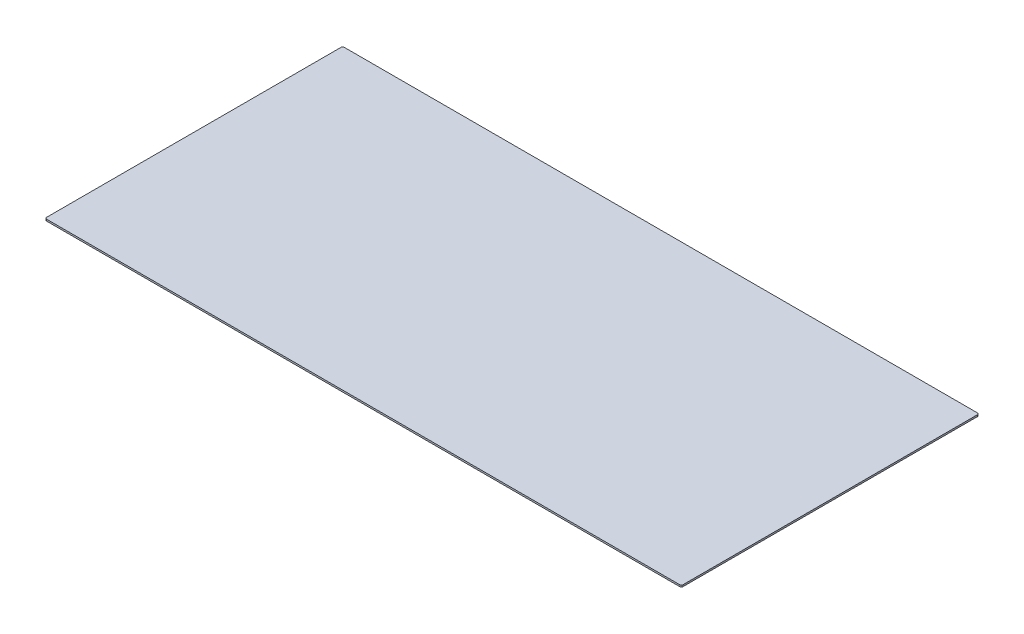
from build123d import *

# Parameters (mm, degrees)
BOSS_EXTRUDE1_DEPTH = 3.175


with BuildPart() as part:
    # Sketch1 → Boss-Extrude1 (new body)
    with BuildSketch(Plane(origin=(0, 0, 0), x_dir=(1, 0, 0), z_dir=(0, 1, 0))):
        with BuildLine():
            Line((-587.375, -276.225), (587.375, -276.225))
            ThreePointArc((587.375, -276.225), (589.62006403, -275.29506403), (590.55, -273.05))
            Line((590.55, -273.05), (590.55, 273.05))
            ThreePointArc((590.55, 273.05), (589.62006403, 275.29506403), (587.375, 276.225))
            Line((587.375, 276.225), (-587.375, 276.225))
            ThreePointArc((-587.375, 276.225), (-589.62006403, 275.29506403), (-590.55, 273.05))
            Line((-590.55, 273.05), (-590.55, -273.05))
            ThreePointArc((-590.55, -273.05), (-589.62006403, -275.29506403), (-587.375, -276.225))
        make_face()
    extrude(amount=BOSS_EXTRUDE1_DEPTH)


solid = part.part
